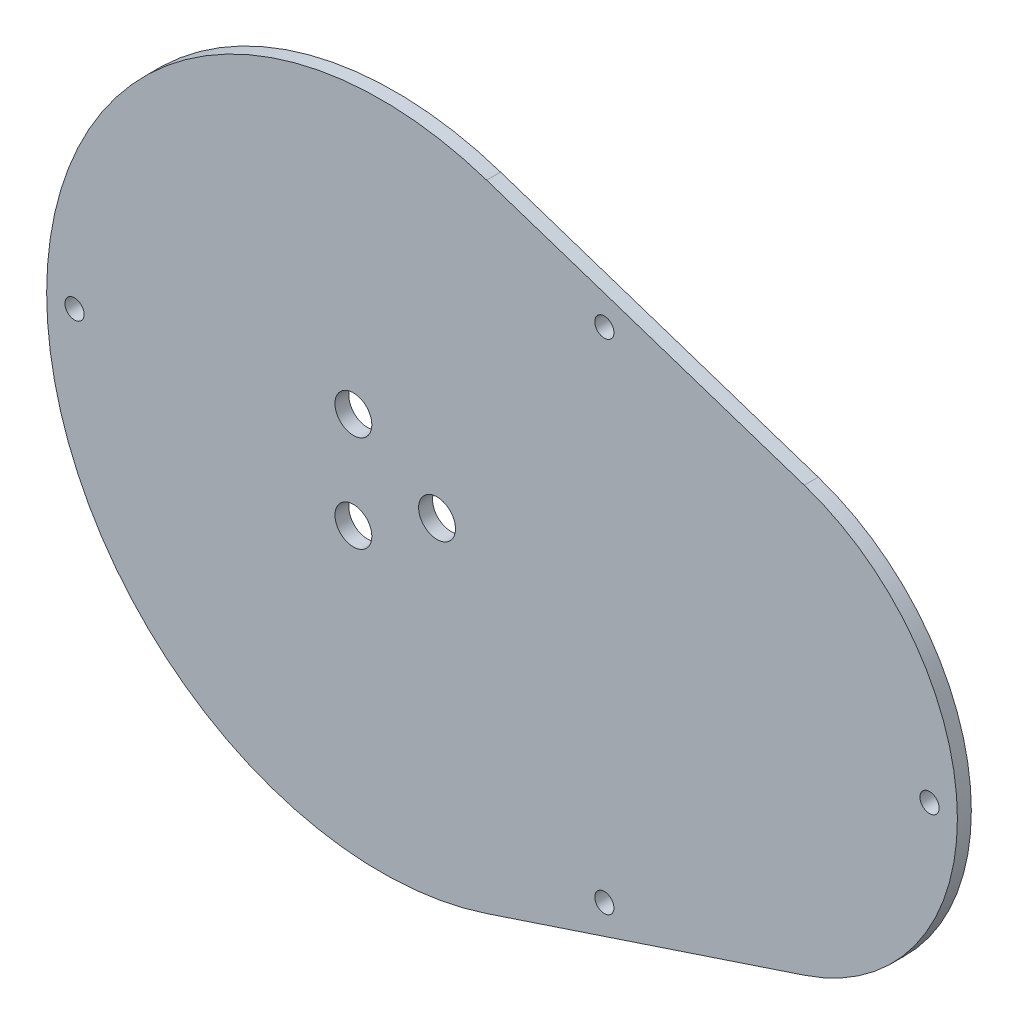
from build123d import *

# Parameters (mm, degrees)
SKETCH1_R           = 1.0922
SKETCH1_R_2         = 2.1
BOSS_EXTRUDE1_DEPTH = 1.5875


with BuildPart() as part:
    # Sketch1 → Boss-Extrude1 (new body)
    with BuildSketch(Plane.XY):
        with BuildLine():
            Line((12.000049197, 36.16087415), (48.160923347, 24.160824953))
            ThreePointArc((48.160923347, 24.160824953), (65.599559924, 0), (48.160923347, -24.160824953))
            Line((48.160923347, -24.160824953), (12.000049197, -36.16087415))
            ThreePointArc((12.000049197, -36.16087415), (-38.1, 0), (12.000049197, 36.16087415))
        make_face()
        with Locations((62.424559924, 0)):
            Circle(SKETCH1_R, mode=Mode.SUBTRACT)
        with Locations((25.4, 28.368817804)):
            Circle(SKETCH1_R, mode=Mode.SUBTRACT)
        with Locations((25.4, -28.368817804)):
            Circle(SKETCH1_R, mode=Mode.SUBTRACT)
        with Locations((-34.925, 0)):
            Circle(SKETCH1_R, mode=Mode.SUBTRACT)
        with Locations((6.35, 0)):
            Circle(SKETCH1_R_2, mode=Mode.SUBTRACT)
        with Locations((-3.175, -5.499261314)):
            Circle(SKETCH1_R_2, mode=Mode.SUBTRACT)
        with Locations((-3.175, 5.499261314)):
            Circle(SKETCH1_R_2, mode=Mode.SUBTRACT)
    extrude(amount=BOSS_EXTRUDE1_DEPTH)


solid = part.part
